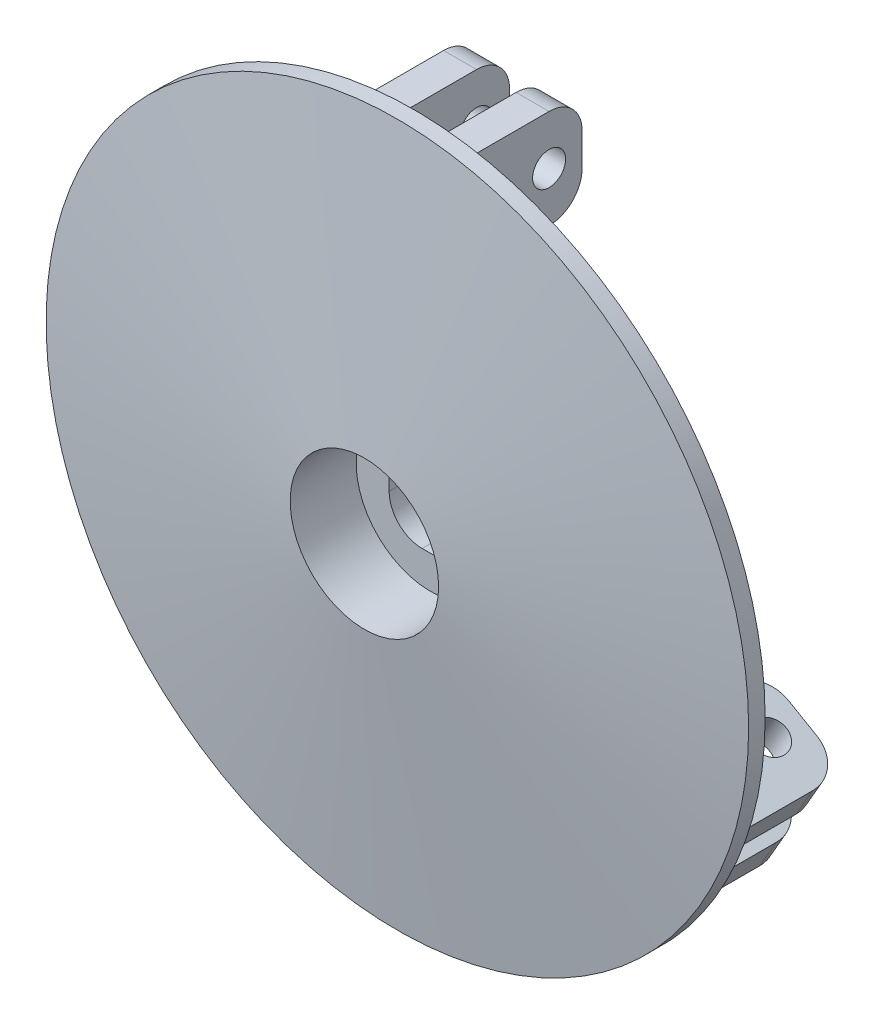
from build123d import *

# Parameters (mm, degrees)
SKETCH1_R                = 22.5
BOSS_EXTRUDE1_DEPTH      = 15
SKETCH4_R                = 25
BOSS_EXTRUDE2_DEPTH      = 30
BOSS_EXTRUDE2_DEPTH_BACK = 10
SKETCH1_3_R              = 22.5
CUT_EXTRUDE1_DEPTH       = 5
SKETCH1_4_R              = 22.5
CUT_EXTRUDE2_DEPTH       = 15
BOSS_EXTRUDE3_START      = -30
SKETCH10_W               = 10
SKETCH10_H               = 30
BOSS_EXTRUDE3_DEPTH      = 39.101444
FILLET1_R                = 10
SKETCH11_R               = 5
CUT_EXTRUDE3_DEPTH       = 32
CIRPATTERN1_COUNT        = 3
FILLET1_OF_CIRPATTERN1_R = 10
FILLET2_R                = 10


with BuildPart() as part:
    # Sketch1 → Boss-Extrude1 (new body)
    with BuildSketch(Plane.XY):
        Circle(SKETCH1_R)
    extrude(amount=BOSS_EXTRUDE1_DEPTH)

    # Sketch3 → Revolve1 (revolve)
    with BuildSketch(Plane(origin=(0, 0, 0), x_dir=(0, 0, -1), z_dir=(1, 0, 0))):
        Polygon((-5, 106.5), (-15, 22.5), (-9.964693814, 22.5), (0, 106.203428035), (0, 106.5), align=None)
    revolve(axis=Axis((0, 0, 15), (0, 0, -1)))

    # Sketch4 → Boss-Extrude2 (add, two sides)
    with BuildSketch(Plane(origin=(0, 0, 0), x_dir=(-1, 0, 0), z_dir=(0, 0, -1))) as boss_extrude2_sk:
        Circle(SKETCH4_R)
        with BuildLine():
            Line((-2.5, 12.5), (2.5, 12.5))
            ThreePointArc((2.5, 12.5), (9.571067812, 9.571067812), (12.5, 2.5))
            Line((12.5, 2.5), (12.5, -2.5))
            ThreePointArc((12.5, -2.5), (9.571067812, -9.571067812), (2.5, -12.5))
            Line((2.5, -12.5), (-2.5, -12.5))
            ThreePointArc((-2.5, -12.5), (-9.571067812, -9.571067812), (-12.5, -2.5))
            Line((-12.5, -2.5), (-12.5, 2.5))
            ThreePointArc((-12.5, 2.5), (-9.571067812, 9.571067812), (-2.5, 12.5))
        make_face(mode=Mode.SUBTRACT)
    extrude(amount=BOSS_EXTRUDE2_DEPTH)
    extrude(boss_extrude2_sk.sketch, amount=-BOSS_EXTRUDE2_DEPTH_BACK)

    # Sketch1_3 → Cut-Extrude1 (cut)
    with BuildSketch(Plane.XY):
        Circle(SKETCH1_3_R)
    extrude(amount=-CUT_EXTRUDE1_DEPTH, mode=Mode.SUBTRACT)

    # Sketch1_4 → Cut-Extrude2 (cut)
    with BuildSketch(Plane.XY):
        Circle(SKETCH1_4_R)
    extrude(amount=CUT_EXTRUDE2_DEPTH, mode=Mode.SUBTRACT)

    # Sketch10 → Boss-Extrude3 (add)
    with BuildSketch(Plane.XY.offset(-5).offset(BOSS_EXTRUDE3_START)):
        with Locations((-11, 86.5)):
            Rectangle(SKETCH10_W, SKETCH10_H)
        with Locations((11, 86.5)):
            Rectangle(SKETCH10_W, SKETCH10_H)
    boss_extrude3 = extrude(amount=BOSS_EXTRUDE3_DEPTH)

    # Fillet1
    fillet1_edges = [part.edges().sort_by_distance(p)[0] for p in [
        (-11, 101.5, -35),
        (-11, 71.5, -35),
        (11, 101.5, -35),
        (11, 71.5, -35),
    ]]
    fillet(fillet1_edges, radius=FILLET1_R)

    # Sketch11 → Cut-Extrude3 (cut)
    with BuildSketch(Plane.ZY.offset(16)):
        with Locations((-25, 86.5)):
            Circle(SKETCH11_R)
    cut_extrude3 = extrude(amount=-CUT_EXTRUDE3_DEPTH, mode=Mode.SUBTRACT)

    # CirPattern1: Boss-Extrude3, Cut-Extrude3 ×3 about axis
    cirpattern1_axis = Axis((0, 0, 0), (0, 0, 1))
    for i in range(1, CIRPATTERN1_COUNT):
        add(boss_extrude3.rotate(cirpattern1_axis, i * 360 / CIRPATTERN1_COUNT))
        add(cut_extrude3.rotate(cirpattern1_axis, i * 360 / CIRPATTERN1_COUNT), mode=Mode.SUBTRACT)

    # Fillet1 of CirPattern1
    fillet1_of_cirpattern1_edges = [part.edges().sort_by_distance(p)[0] for p in [
        (-82.401578484, -60.276279442, -35),
        (-56.420816371, -45.276279442, -35),
        (-93.401578484, -41.223720558, -35),
        (-67.420816371, -26.223720558, -35),
        (93.401578484, -41.223720558, -35),
        (67.420816371, -26.223720558, -35),
        (82.401578484, -60.276279442, -35),
        (56.420816371, -45.276279442, -35),
    ]]
    fillet(fillet1_of_cirpattern1_edges, radius=FILLET1_OF_CIRPATTERN1_R)

    # Fillet2
    fillet2_edges = [part.edges().sort_by_distance(p)[0] for p in [
        (25, 0, -30),
    ]]
    fillet(fillet2_edges, radius=FILLET2_R)


solid = part.part
